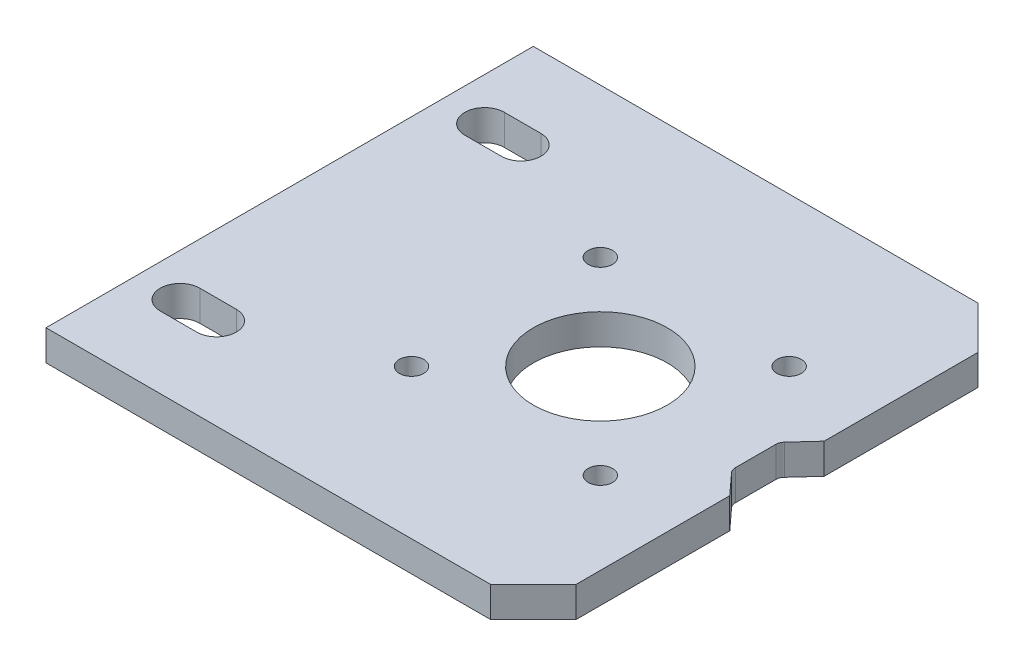
from build123d import *

# Parameters (mm, degrees)
SCHIZZO1_W                   = 80
SCHIZZO1_H                   = 5
ESTRUSIONE_ESTRUSIONE1_DEPTH = 80
SCHIZZO4_R                   = 11
TAGLIO_ESTRUSIONE1_DEPTH     = 6
SCHIZZO6_R                   = 2
TAGLIO_ESTRUSIONE3_DEPTH     = 6
CHAMFER1_SIZE                = 7
CUT_EXTRUDE1_DEPTH           = 6
CUT_EXTRUDE2_DEPTH           = 6
FILLET1_R                    = 1.5
FILLET2_R                    = 1.5


with BuildPart() as part:
    # Schizzo1 → Estrusione-Estrusione1 (new body)
    with BuildSketch(Plane.XY):
        with Locations((40, 2.5)):
            Rectangle(SCHIZZO1_W, SCHIZZO1_H)
    extrude(amount=ESTRUSIONE_ESTRUSIONE1_DEPTH)

    # Schizzo4 → Taglio-Estrusione1 (cut, through all)
    with BuildSketch(Plane(origin=(0, 5, 0), x_dir=(1, 0, 0), z_dir=(0, 1, 0))):
        with Locations((51, -40)):
            Circle(SCHIZZO4_R)
    extrude(amount=-TAGLIO_ESTRUSIONE1_DEPTH, mode=Mode.SUBTRACT)

    # Schizzo6 → Taglio-Estrusione3 (cut, through all)
    with BuildSketch(Plane(origin=(0, 5, 0), x_dir=(1, 0, 0), z_dir=(0, 1, 0))):
        with Locations((35.5, -24.5)):
            Circle(SCHIZZO6_R)
        with Locations((66.5, -24.5)):
            Circle(SCHIZZO6_R)
        with Locations((66.5, -55.5)):
            Circle(SCHIZZO6_R)
        with Locations((35.5, -55.5)):
            Circle(SCHIZZO6_R)
    extrude(amount=-TAGLIO_ESTRUSIONE3_DEPTH, mode=Mode.SUBTRACT)

    # Chamfer1
    chamfer1_edges = [part.edges().sort_by_distance(p)[0] for p in [
        (80, 2.5, 80),
        (80, 2.5, 0),
    ]]
    chamfer(chamfer1_edges, length=CHAMFER1_SIZE)

    # Sketch1 → Cut-Extrude1 (cut, through all)
    with BuildSketch(Plane(origin=(0, 5, 0), x_dir=(1, 0, 0), z_dir=(0, 1, 0))):
        with BuildLine():
            Line((7, -11.75), (13, -11.75))
            ThreePointArc((13, -11.75), (16.25, -15), (13, -18.25))
            Line((13, -18.25), (7, -18.25))
            ThreePointArc((7, -18.25), (3.75, -15), (7, -11.75))
        make_face()
        with BuildLine():
            Line((7, -68.25), (13, -68.25))
            ThreePointArc((13, -68.25), (16.25, -65), (13, -61.75))
            Line((13, -61.75), (7, -61.75))
            ThreePointArc((7, -61.75), (3.75, -65), (7, -68.25))
        make_face()
    extrude(amount=-CUT_EXTRUDE1_DEPTH, mode=Mode.SUBTRACT)

    # Sketch2 → Cut-Extrude2 (cut, through all)
    with BuildSketch(Plane(origin=(0, 5, 0), x_dir=(1, 0, 0), z_dir=(0, 1, 0))):
        Polygon((80, -32.245982949), (76.480308406, -36.096971283), (76.480308406, -43.903028717), (80, -47.754017051), align=None)
    extrude(amount=-CUT_EXTRUDE2_DEPTH, mode=Mode.SUBTRACT)

    # Fillet1
    fillet1_edges = [part.edges().sort_by_distance(p)[0] for p in [
        (76.480308406, 2.5, 36.096971283),
    ]]
    fillet(fillet1_edges, radius=FILLET1_R)

    # Fillet2
    fillet2_edges = [part.edges().sort_by_distance(p)[0] for p in [
        (76.480308406, 2.5, 43.903028717),
    ]]
    fillet(fillet2_edges, radius=FILLET2_R)


solid = part.part
